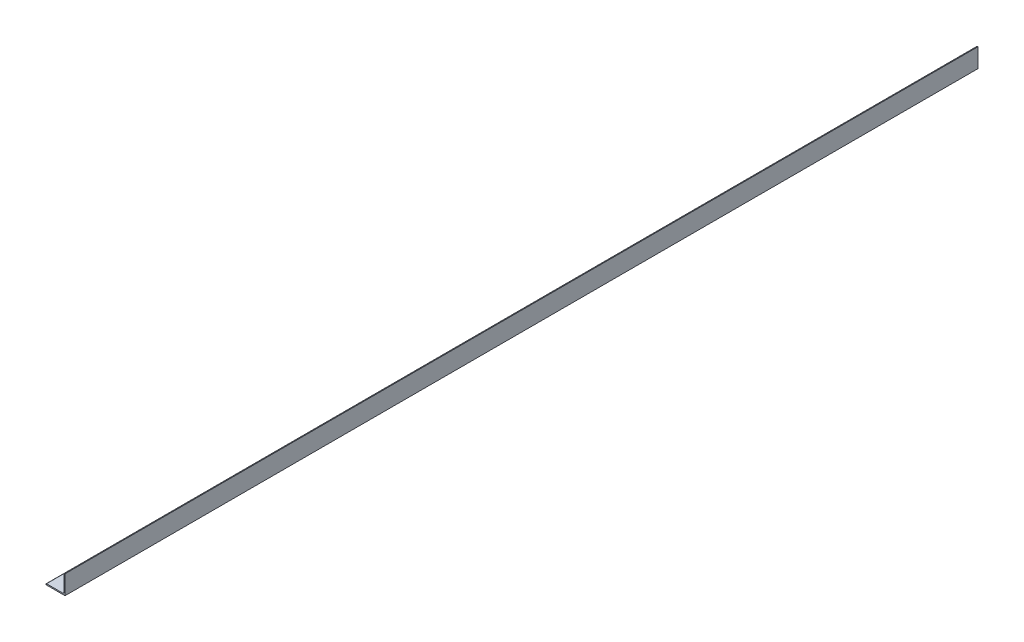
from build123d import *

# Parameters (mm, degrees)
BOSS_EXTRUDE1_DEPTH = 609.6


with BuildPart() as part:
    # Sketch2 → Boss-Extrude1 (new, symmetric)
    with BuildSketch(Plane.XY):
        with BuildLine():
            Line((-12.7, -12.7), (12.7, -12.7))
            Line((12.7, -12.7), (12.7, 12.7))
            Line((12.7, 12.7), (11.90625, 12.7))
            ThreePointArc((11.90625, 12.7), (11.344983992, 12.467516008), (11.1125, 11.90625))
            Line((11.1125, 11.90625), (11.1125, -9.5377))
            ThreePointArc((11.1125, -9.5377), (10.651251759, -10.651251759), (9.5377, -11.1125))
            Line((9.5377, -11.1125), (-11.90625, -11.1125))
            ThreePointArc((-11.90625, -11.1125), (-12.467516008, -11.344983992), (-12.7, -11.90625))
            Line((-12.7, -11.90625), (-12.7, -12.7))
        make_face()
    extrude(amount=BOSS_EXTRUDE1_DEPTH, both=True)


solid = part.part
